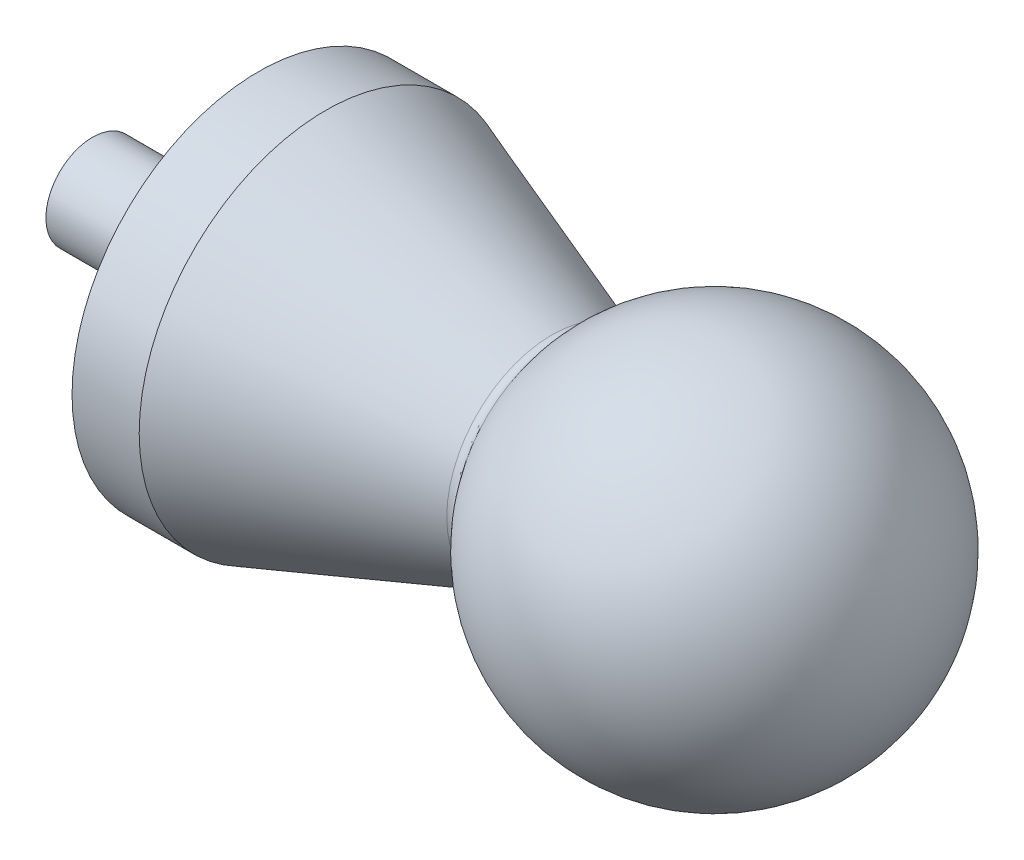
from build123d import *

# Parameters (mm, degrees)
FILLET1_R = 2


with BuildPart() as part:
    # Sketch1 → Revolve1 (revolve)
    with BuildSketch(Plane(origin=(0, 0, 0), x_dir=(1, 0, 0), z_dir=(0, 1, 0))):
        with BuildLine():
            Line((-83.333328339, 39.999998202), (-33.392539812, 22.021314332))
            ThreePointArc((-33.392539812, 22.021314332), (11.49561672, 38.312540979), (40, 0))
            Line((40, 0), (-133.33332, 0))
            Line((-133.33332, 0), (-133.33332, 9.999999))
            Line((-133.33332, 9.999999), (-97.73332356, 9.999999))
            Line((-97.73332356, 9.999999), (-97.73332356, 39.999998202))
            Line((-97.73332356, 39.999998202), (-83.333328339, 39.999998202))
        make_face()
    revolve(axis=Axis((25.002810952, 0, 0), (-1, 0, 0)))

    # Fillet1
    fillet1_edges = [part.edges().sort_by_distance(p)[0] for p in [
        (-33.392539812, 0, 22.021314332),
    ]]
    fillet(fillet1_edges, radius=FILLET1_R)


solid = part.part
